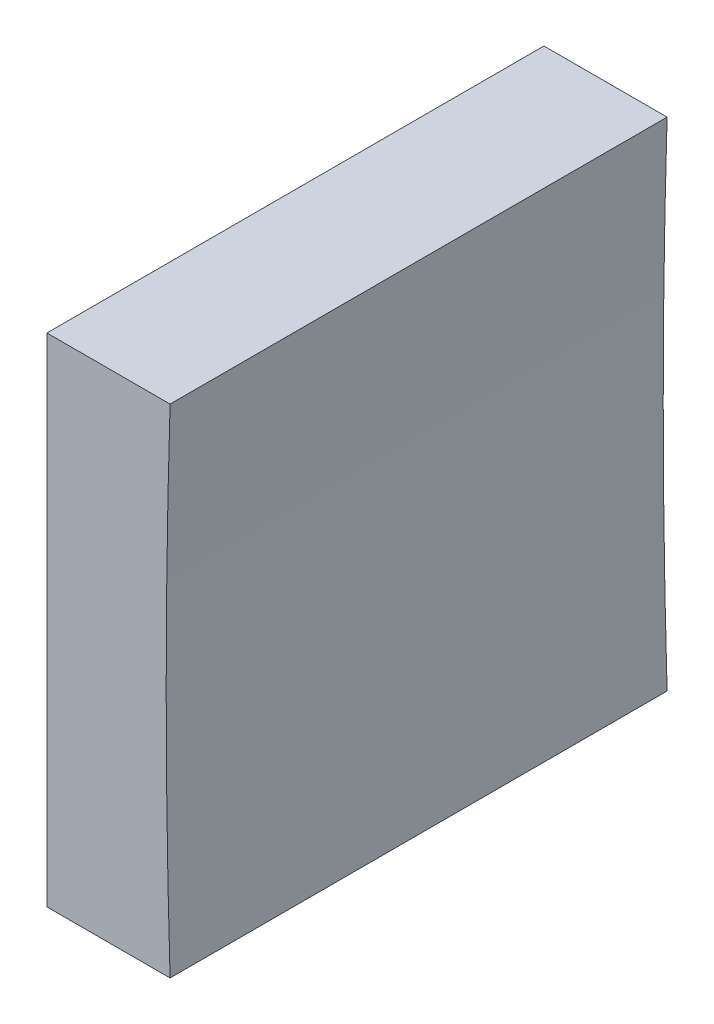
from build123d import *

# Parameters (mm, degrees)
EXTRUDE_1_DEPTH = 25


with BuildPart() as part:
    # 草图1 → 凸台-拉伸1 (new body)
    with BuildSketch(Plane.XY):
        with BuildLine():
            Line((284.707135631, 66.857929268), (284.707135631, 79.357929268))
            Line((284.707135631, 79.357929268), (290.902495825, 79.357929268))
            ThreePointArc((290.902495825, 79.357929268), (290.707135618, 66.857929268), (290.902495825, 54.357929268))
            Line((290.902495825, 54.357929268), (284.707135631, 54.357929268))
            Line((284.707135631, 54.357929268), (284.707135631, 66.857929268))
        make_face()
    extrude(amount=EXTRUDE_1_DEPTH)


solid = part.part
